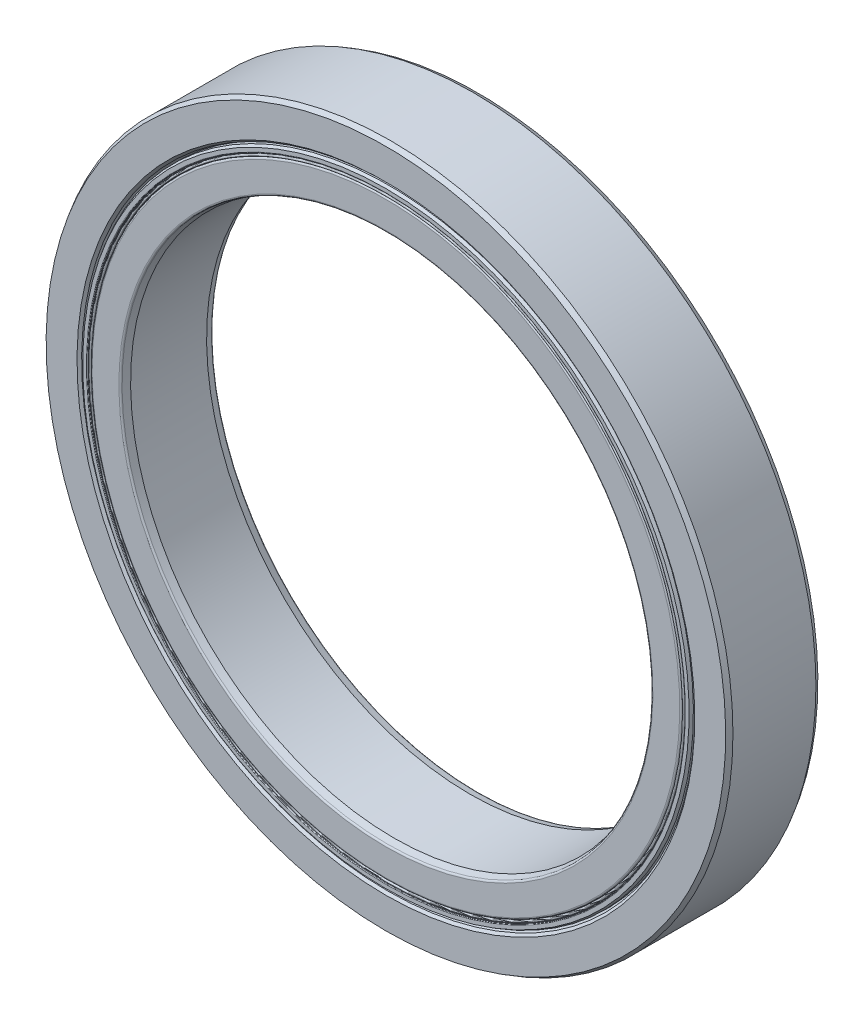
from build123d import *

# Parameters (mm, degrees)
CIRPATTERN1_COUNT = 20


with BuildPart() as part:
    # Sketch3 → Revolve1 (revolve)
    with BuildSketch(Plane(origin=(0, 0, 0), x_dir=(0, 0, -1), z_dir=(1, 0, 0))):
        with BuildLine():
            Line((-2.945227749, 23.14), (-3.325, 23.278225795))
            Line((-3.325, 23.278225795), (-3.5, 23.453225795))
            Line((-3.5, 23.453225795), (-3.5, 25.797927406))
            Line((-3.5, 25.797927406), (-3.15, 26))
            Line((-3.15, 26), (3.15, 26))
            Line((3.15, 26), (3.5, 25.797927406))
            Line((3.5, 25.797927406), (3.5, 23.453225795))
            Line((3.5, 23.453225795), (3.325, 23.278225795))
            Line((3.325, 23.278225795), (2.945227749, 23.14))
            Line((2.945227749, 23.14), (2.223650652, 23.14))
            ThreePointArc((2.223650652, 23.14), (0, 25.046666667), (-2.223650652, 23.14))
            Line((-2.223650652, 23.14), (-2.945227749, 23.14))
        make_face()
    revolve(axis=Axis((0, 0, 3.5), (0, 0, -1)))


with BuildPart() as body_2:
    # Sketch4 → Revolve2 (revolve)
    with BuildSketch(Plane(origin=(0, 0, 0), x_dir=(0, 0, -1), z_dir=(1, 0, 0))):
        with BuildLine():
            Line((-2.885085035, 20), (-3.395131978, 20.136666667))
            ThreePointArc((-3.395131978, 20.136666667), (-3.47076203, 20.187201052), (-3.5, 20.273333333))
            Line((-3.5, 20.273333333), (-3.5, 22.311845589))
            ThreePointArc((-3.5, 22.311845589), (-3.458559199, 22.411892532), (-3.358512255, 22.453333333))
            Line((-3.358512255, 22.453333333), (-2.223650652, 22.453333333))
            ThreePointArc((-2.223650652, 22.453333333), (0, 20.546666667), (2.223650652, 22.453333333))
            Line((2.223650652, 22.453333333), (3.358512255, 22.453333333))
            ThreePointArc((3.358512255, 22.453333333), (3.458559199, 22.411892532), (3.5, 22.311845589))
            Line((3.5, 22.311845589), (3.5, 20.273333333))
            ThreePointArc((3.5, 20.273333333), (3.47076203, 20.187201052), (3.395131978, 20.136666667))
            Line((3.395131978, 20.136666667), (2.885085035, 20))
            Line((2.885085035, 20), (-2.885085035, 20))
        make_face()
    revolve(axis=Axis((0, 0, 3.5), (0, 0, -1)))


with BuildPart() as body_3:
    # Sketch5 → Revolve3 (revolve)
    with BuildSketch(Plane(origin=(0, 0, 0), x_dir=(0, 0, -1), z_dir=(1, 0, 0))):
        with BuildLine():
            Line((-2.25, 22.796666667), (2.25, 22.796666667))
            ThreePointArc((2.25, 22.796666667), (0, 25.046666667), (-2.25, 22.796666667))
        make_face()
    revolve(axis=Axis((0, 22.796666667, 2.25), (0, 0, -1)))


with BuildPart() as cirpattern1_1:
    # CirPattern1: pattern copy
    add(body_3.part.rotate(Axis((0, 0, 3.5), (0, 0, -1)), 1 * 360 / CIRPATTERN1_COUNT))


with BuildPart() as cirpattern1_2:
    # CirPattern1: pattern copy
    add(body_3.part.rotate(Axis((0, 0, 3.5), (0, 0, -1)), 2 * 360 / CIRPATTERN1_COUNT))


with BuildPart() as cirpattern1_3:
    # CirPattern1: pattern copy
    add(body_3.part.rotate(Axis((0, 0, 3.5), (0, 0, -1)), 3 * 360 / CIRPATTERN1_COUNT))


with BuildPart() as cirpattern1_4:
    # CirPattern1: pattern copy
    add(body_3.part.rotate(Axis((0, 0, 3.5), (0, 0, -1)), 4 * 360 / CIRPATTERN1_COUNT))


with BuildPart() as cirpattern1_5:
    # CirPattern1: pattern copy
    add(body_3.part.rotate(Axis((0, 0, 3.5), (0, 0, -1)), 5 * 360 / CIRPATTERN1_COUNT))


with BuildPart() as cirpattern1_6:
    # CirPattern1: pattern copy
    add(body_3.part.rotate(Axis((0, 0, 3.5), (0, 0, -1)), 6 * 360 / CIRPATTERN1_COUNT))


with BuildPart() as cirpattern1_7:
    # CirPattern1: pattern copy
    add(body_3.part.rotate(Axis((0, 0, 3.5), (0, 0, -1)), 7 * 360 / CIRPATTERN1_COUNT))


with BuildPart() as cirpattern1_8:
    # CirPattern1: pattern copy
    add(body_3.part.rotate(Axis((0, 0, 3.5), (0, 0, -1)), 8 * 360 / CIRPATTERN1_COUNT))


with BuildPart() as cirpattern1_9:
    # CirPattern1: pattern copy
    add(body_3.part.rotate(Axis((0, 0, 3.5), (0, 0, -1)), 9 * 360 / CIRPATTERN1_COUNT))


with BuildPart() as cirpattern1_10:
    # CirPattern1: pattern copy
    add(body_3.part.rotate(Axis((0, 0, 3.5), (0, 0, -1)), 10 * 360 / CIRPATTERN1_COUNT))


with BuildPart() as cirpattern1_11:
    # CirPattern1: pattern copy
    add(body_3.part.rotate(Axis((0, 0, 3.5), (0, 0, -1)), 11 * 360 / CIRPATTERN1_COUNT))


with BuildPart() as cirpattern1_12:
    # CirPattern1: pattern copy
    add(body_3.part.rotate(Axis((0, 0, 3.5), (0, 0, -1)), 12 * 360 / CIRPATTERN1_COUNT))


with BuildPart() as cirpattern1_13:
    # CirPattern1: pattern copy
    add(body_3.part.rotate(Axis((0, 0, 3.5), (0, 0, -1)), 13 * 360 / CIRPATTERN1_COUNT))


with BuildPart() as cirpattern1_14:
    # CirPattern1: pattern copy
    add(body_3.part.rotate(Axis((0, 0, 3.5), (0, 0, -1)), 14 * 360 / CIRPATTERN1_COUNT))


with BuildPart() as cirpattern1_15:
    # CirPattern1: pattern copy
    add(body_3.part.rotate(Axis((0, 0, 3.5), (0, 0, -1)), 15 * 360 / CIRPATTERN1_COUNT))


with BuildPart() as cirpattern1_16:
    # CirPattern1: pattern copy
    add(body_3.part.rotate(Axis((0, 0, 3.5), (0, 0, -1)), 16 * 360 / CIRPATTERN1_COUNT))


with BuildPart() as cirpattern1_17:
    # CirPattern1: pattern copy
    add(body_3.part.rotate(Axis((0, 0, 3.5), (0, 0, -1)), 17 * 360 / CIRPATTERN1_COUNT))


with BuildPart() as cirpattern1_18:
    # CirPattern1: pattern copy
    add(body_3.part.rotate(Axis((0, 0, 3.5), (0, 0, -1)), 18 * 360 / CIRPATTERN1_COUNT))


with BuildPart() as cirpattern1_19:
    # CirPattern1: pattern copy
    add(body_3.part.rotate(Axis((0, 0, 3.5), (0, 0, -1)), 19 * 360 / CIRPATTERN1_COUNT))


with BuildPart() as body_23:
    # Sketch6 → Revolve4 (revolve)
    with BuildSketch(Plane(origin=(0, 0, 0), x_dir=(0, 0, -1), z_dir=(1, 0, 0))):
        with BuildLine():
            Line((-3.292153903, 23.14), (-2.25, 23.14))
            Line((-2.25, 23.14), (-2.25, 22.693333333))
            Line((-2.25, 22.693333333), (-3.452, 22.693333333))
            ThreePointArc((-3.452, 22.693333333), (-3.485941125, 22.707392208), (-3.5, 22.741333333))
            Line((-3.5, 22.741333333), (-3.5, 23.02))
            Line((-3.5, 23.02), (-3.292153903, 23.14))
        make_face()
        with BuildLine():
            Line((3.452, 22.693333333), (2.25, 22.693333333))
            Line((2.25, 22.693333333), (2.25, 23.14))
            Line((2.25, 23.14), (3.292153903, 23.14))
            Line((3.292153903, 23.14), (3.5, 23.02))
            Line((3.5, 23.02), (3.5, 22.741333333))
            ThreePointArc((3.5, 22.741333333), (3.485941125, 22.707392208), (3.452, 22.693333333))
        make_face()
    revolve(axis=Axis((0, 0, 3.5), (0, 0, -1)))


with BuildPart() as body_24:
    # Sketch7 → Revolve5 (revolve)
    with BuildSketch(Plane(origin=(0, 0, 0), x_dir=(0, 0, -1), z_dir=(1, 0, 0))):
        with BuildLine():
            Line((-2.25, 22.693333333), (-3.33024932, 22.693333333))
            Line((-3.33024932, 22.693333333), (-3.389337785, 22.682914443))
            ThreePointArc((-3.389337785, 22.682914443), (-3.409885251, 22.656136464), (-3.385, 22.633333333))
            Line((-3.385, 22.633333333), (-3.41, 22.633333333))
            ThreePointArc((-3.41, 22.633333333), (-3.5, 22.543333333), (-3.41, 22.453333333))
            Line((-3.41, 22.453333333), (-2.25, 22.453333333))
            Line((-2.25, 22.453333333), (-2.25, 22.693333333))
        make_face()
    revolve(axis=Axis((0, 0, 3.5), (0, 0, -1)))


solid = Compound([part.part, body_2.part, body_3.part, cirpattern1_1.part, cirpattern1_2.part, cirpattern1_3.part, cirpattern1_4.part, cirpattern1_5.part, cirpattern1_6.part, cirpattern1_7.part, cirpattern1_8.part, cirpattern1_9.part, cirpattern1_10.part, cirpattern1_11.part, cirpattern1_12.part, cirpattern1_13.part, cirpattern1_14.part, cirpattern1_15.part, cirpattern1_16.part, cirpattern1_17.part, cirpattern1_18.part, cirpattern1_19.part, body_23.part, body_24.part])
